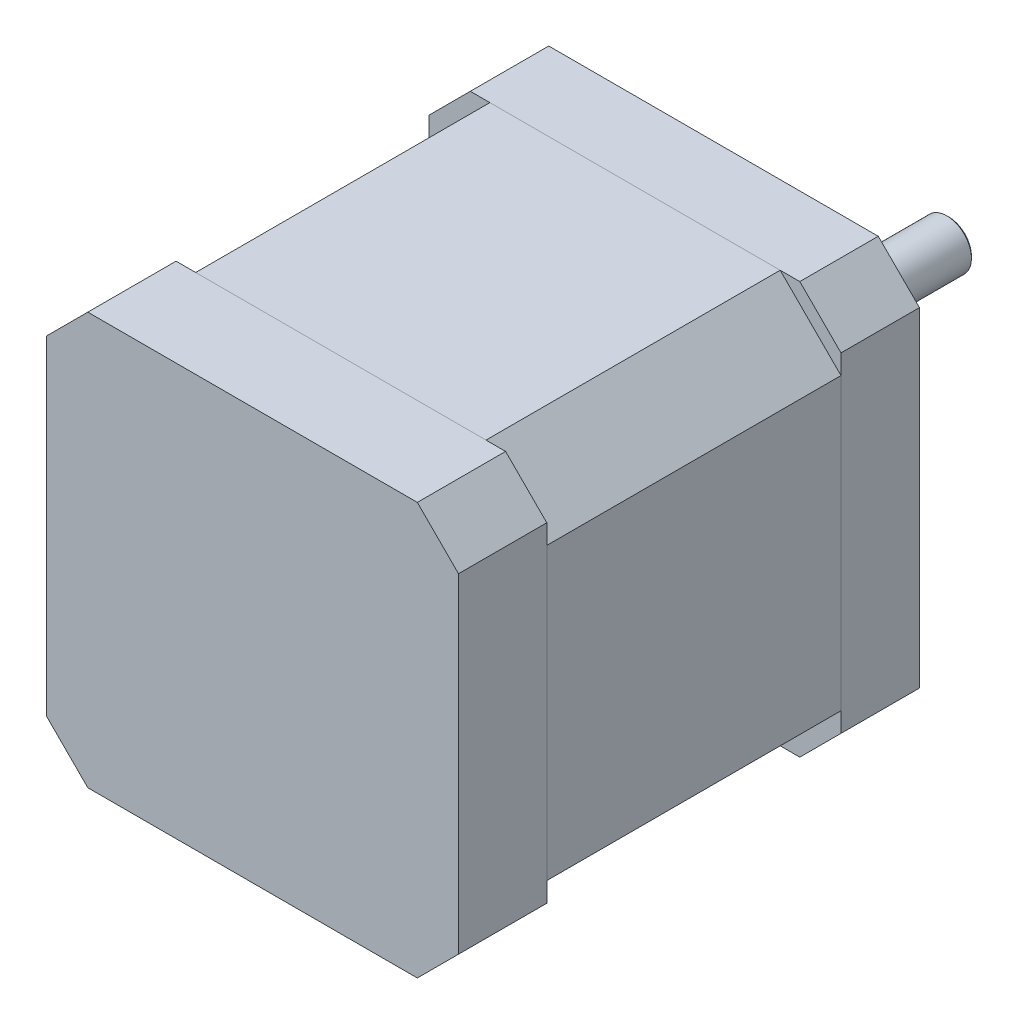
from build123d import *

# Parameters (mm, degrees)
ESQUISSE1_W             = 42
ESQUISSE1_H             = 42
BOSS_EXTRU_1_DEPTH      = 8
CHANFREIN1_SIZE         = 4.2
BOSS_EXTRU_2_DEPTH      = 30
ESQUISSE4_W             = 42
ESQUISSE4_H             = 42
BOSS_EXTRU_3_DEPTH      = 9
CHANFREIN3_SIZE         = 4.2
ESQUISSE5_R             = 11
BOSS_EXTRU_4_DEPTH      = 2
ESQUISSE6_R             = 4.5
ENL_V_MAT_EXTRU_1_DEPTH = 3
ESQUISSE7_R             = 2.5
BOSS_EXTRU_5_DEPTH      = 25
CHANFREIN4_SIZE         = 0.2
ESQUISSE8_R             = 1.5
ENL_V_MAT_EXTRU_2_DEPTH = 5
CHANFREIN5_SIZE         = 0.2
ESQUISSE9_W             = 7
ESQUISSE9_H             = 8
ENL_V_MAT_EXTRU_3_DEPTH = 2


with BuildPart() as part:
    # Esquisse1 → Boss.-Extru.1 (new body)
    with BuildSketch(Plane.XY):
        Rectangle(ESQUISSE1_W, ESQUISSE1_H)
    extrude(amount=BOSS_EXTRU_1_DEPTH)

    # Chanfrein1
    chanfrein1_edges = [part.edges().sort_by_distance(p)[0] for p in [
        (21, -21, 4),
        (-21, -21, 4),
        (-21, 21, 4),
        (21, 21, 4),
    ]]
    chamfer(chanfrein1_edges, length=CHANFREIN1_SIZE)

    # Esquisse5 → Boss.-Extru.4 (add)
    with BuildSketch(Plane(origin=(0, 0, 0), x_dir=(-1, 0, 0), z_dir=(0, 0, -1))):
        Circle(ESQUISSE5_R)
    extrude(amount=BOSS_EXTRU_4_DEPTH)

    # Esquisse6 → Enlèv. mat.-Extru.1 (cut)
    with BuildSketch(Plane(origin=(0, 0, -2), x_dir=(-1, 0, 0), z_dir=(0, 0, -1))):
        Circle(ESQUISSE6_R)
    extrude(amount=-ENL_V_MAT_EXTRU_1_DEPTH, mode=Mode.SUBTRACT)

    # Esquisse7 → Boss.-Extru.5 (add)
    with BuildSketch(Plane(origin=(0, 0, 1), x_dir=(-1, 0, 0), z_dir=(0, 0, -1))):
        Circle(ESQUISSE7_R)
    extrude(amount=BOSS_EXTRU_5_DEPTH)

    # Chanfrein4
    chanfrein4_edges = [part.edges().sort_by_distance(p)[0] for p in [
        (2.5, 0, -24),
    ]]
    chamfer(chanfrein4_edges, length=CHANFREIN4_SIZE)

    # Esquisse8 → Enlèv. mat.-Extru.2 (cut)
    with BuildSketch(Plane(origin=(0, 0, 0), x_dir=(-1, 0, 0), z_dir=(0, 0, -1))):
        with Locations((-15.5, 15.5)):
            Circle(ESQUISSE8_R)
        with Locations((15.5, 15.5)):
            Circle(ESQUISSE8_R)
        with Locations((15.5, -15.5)):
            Circle(ESQUISSE8_R)
        with Locations((-15.5, -15.5)):
            Circle(ESQUISSE8_R)
    extrude(amount=-ENL_V_MAT_EXTRU_2_DEPTH, mode=Mode.SUBTRACT)

    # Chanfrein5
    chanfrein5_edges = [part.edges().sort_by_distance(p)[0] for p in [
        (17, 15.5, 0),
        (-14, 15.5, 0),
        (-14, -15.5, 0),
        (17, -15.5, 0),
    ]]
    chamfer(chanfrein5_edges, length=CHANFREIN5_SIZE)


with BuildPart() as body_2:
    # Esquisse3 → Boss.-Extru.2 (new body)
    with BuildSketch(Plane.XY.offset(8)):
        Polygon((-21, 14.8), (-14.8, 21), (14.8, 21), (21, 14.8), (21, -14.8), (14.8, -21), (-14.8, -21), (-21, -14.8), align=None)
    extrude(amount=BOSS_EXTRU_2_DEPTH)


with BuildPart() as body_3:
    # Esquisse4 → Boss.-Extru.3 (new body)
    with BuildSketch(Plane.XY.offset(38)):
        Rectangle(ESQUISSE4_W, ESQUISSE4_H)
    extrude(amount=BOSS_EXTRU_3_DEPTH)

    # Chanfrein3
    chanfrein3_edges = [body_3.edges().sort_by_distance(p)[0] for p in [
        (21, -21, 42.5),
        (-21, -21, 42.5),
        (-21, 21, 42.5),
        (21, 21, 42.5),
    ]]
    chamfer(chanfrein3_edges, length=CHANFREIN3_SIZE)

    # Esquisse9 → Enlèv. mat.-Extru.3 (cut)
    with BuildSketch(Plane.ZY.offset(21)):
        with Locations((41.5, 0)):
            Rectangle(ESQUISSE9_W, ESQUISSE9_H)
    extrude(amount=-ENL_V_MAT_EXTRU_3_DEPTH, mode=Mode.SUBTRACT)


solid = Compound([part.part, body_2.part, body_3.part])
